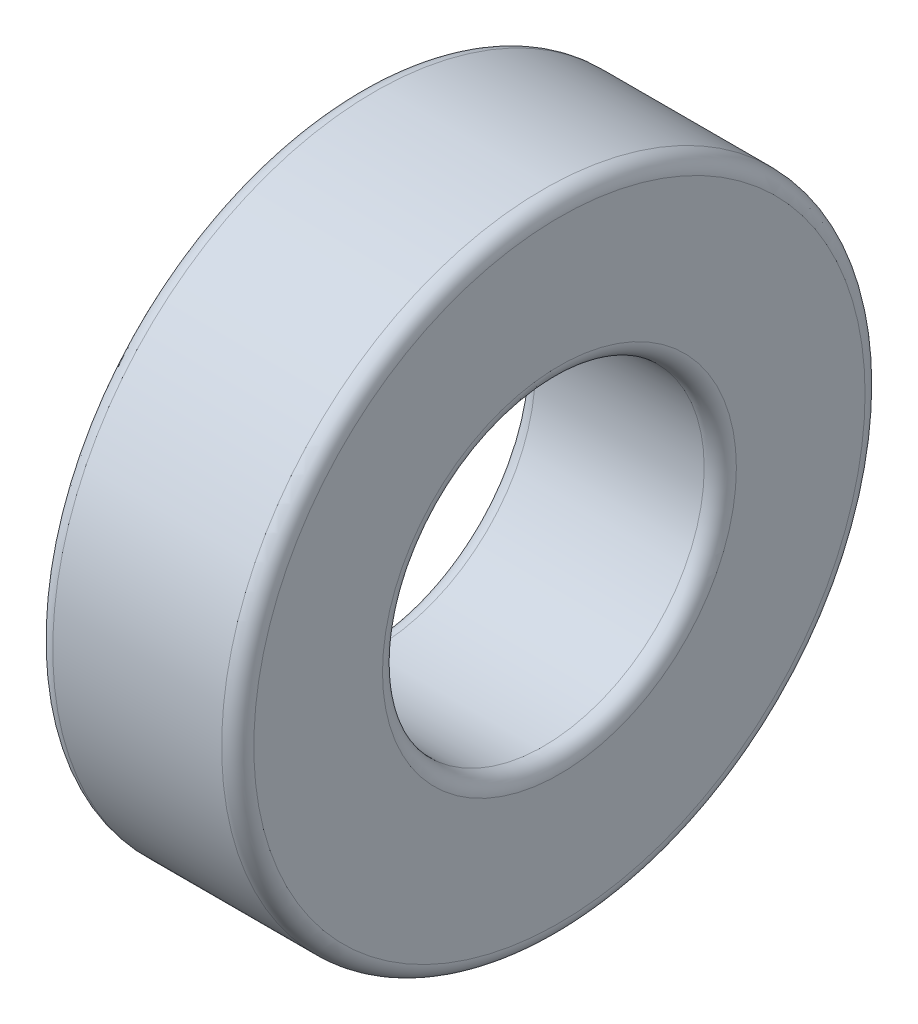
from build123d import *

# Parameters (mm, degrees)
CROQUIS1_R              = 8
CROQUIS1_R_2            = 4
SALIENTE_EXTRUIR1_DEPTH = 5
REDONDEO1_R             = 0.4


with BuildPart() as part:
    # Croquis1 → Saliente-Extruir1 (new body)
    with BuildSketch(Plane(origin=(0, 0, 0), x_dir=(0, 0, -1), z_dir=(1, 0, 0))):
        Circle(CROQUIS1_R)
        Circle(CROQUIS1_R_2, mode=Mode.SUBTRACT)
    extrude(amount=SALIENTE_EXTRUIR1_DEPTH)

    # Redondeo1
    redondeo1_edges = [part.edges().sort_by_distance(p)[0] for p in [
        (0, 0, 8),
        (5, 0, 8),
        (0, 0, 4),
        (5, 0, 4),
    ]]
    fillet(redondeo1_edges, radius=REDONDEO1_R)


solid = part.part
